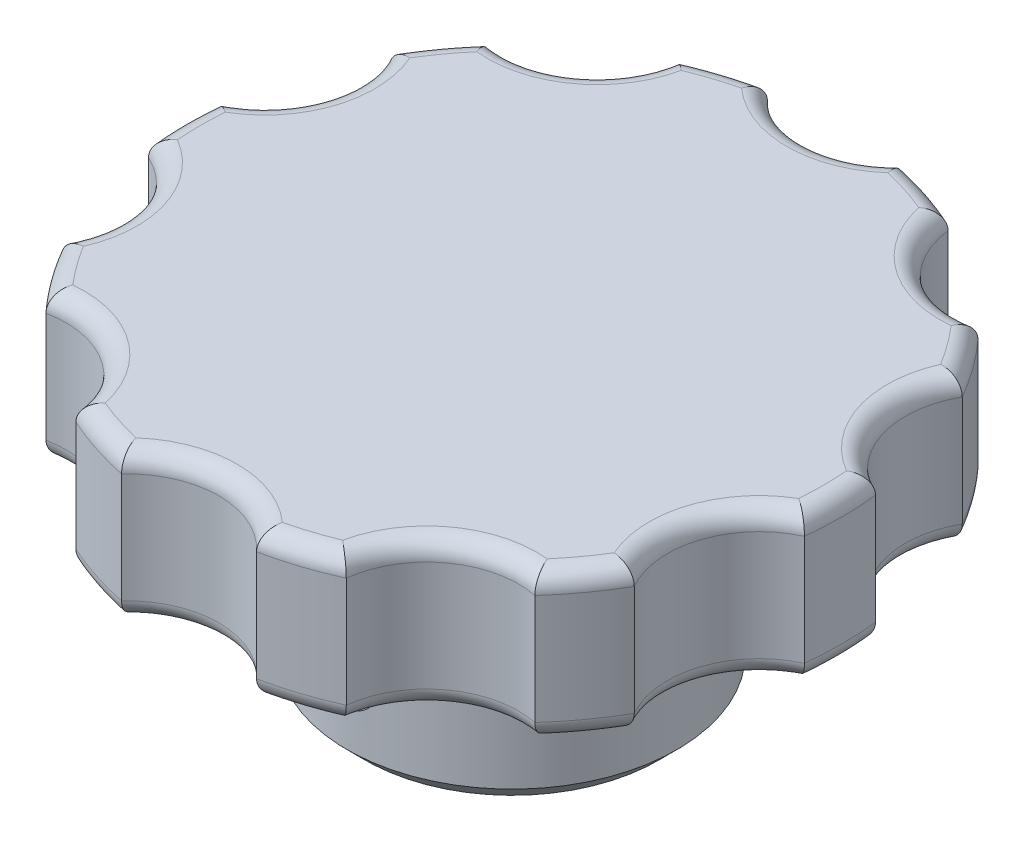
from build123d import *

# Parameters (mm, degrees)
CUT_EXTRUDE1_DEPTH = 18.5
CIRPATTERN1_COUNT  = 10
FILLET1_R          = 1
CHAMFER1_SIZE      = 1
SKETCH4_R          = 1.5
CUT_EXTRUDE2_DEPTH = 10


with BuildPart() as part:
    # Sketch1 → Revolve1 (revolve)
    with BuildSketch(Plane.XY):
        Polygon((-6, 0), (-6, 14), (0, 14), (0, 17.5), (-18, 17.5), (-18, 9.5), (-9, 9.5), (-9, 0), align=None)
    revolve(axis=Axis((0, 38.886792453, 0), (0, -1, 0)))

    # Sketch2 → Cut-Extrude1 (cut, through all)
    with BuildSketch(Plane(origin=(0, 17.5, 0), x_dir=(1, 0, 0), z_dir=(0, 1, 0))):
        with BuildLine():
            Line((-5, 21), (5, 21))
            ThreePointArc((5, 21), (0, 16), (-5, 21))
        make_face()
    cut_extrude1 = extrude(amount=-CUT_EXTRUDE1_DEPTH, mode=Mode.SUBTRACT)

    # CirPattern1: Cut-Extrude1 ×10 about axis
    cirpattern1_axis = Axis((0, 0, 0), (0, 1, 0))
    for i in range(1, CIRPATTERN1_COUNT):
        add(cut_extrude1.rotate(cirpattern1_axis, i * 360 / CIRPATTERN1_COUNT), mode=Mode.SUBTRACT)

    # Fillet1
    fillet1_edges = [part.edges().sort_by_distance(p)[0] for p in [
        (-9.404564037, 17.5, -12.94427191),
        (-5.562305899, 9.5, -17.119017293),
        (0, 9.5, -16),
        (-5.562305899, 17.5, -17.119017293),
        (0, 17.5, -16),
        (-14.562305899, 9.5, -10.580134541),
        (-18, 9.5, 0),
        (-14.562305899, 9.5, 10.580134541),
        (-5.562305899, 9.5, 17.119017293),
        (5.562305899, 9.5, 17.119017293),
        (14.562305899, 9.5, 10.580134541),
        (18, 9.5, 0),
        (14.562305899, 9.5, -10.580134541),
        (5.562305899, 9.5, -17.119017293),
        (-9.404564037, 9.5, -12.94427191),
        (-15.216904261, 9.5, -4.94427191),
        (-15.216904261, 9.5, 4.94427191),
        (-9.404564037, 9.5, 12.94427191),
        (0, 9.5, 16),
        (9.404564037, 9.5, 12.94427191),
        (15.216904261, 9.5, 4.94427191),
        (15.216904261, 9.5, -4.94427191),
        (9.404564037, 9.5, -12.94427191),
        (-14.562305899, 17.5, -10.580134541),
        (-18, 17.5, 0),
        (-14.562305899, 17.5, 10.580134541),
        (-5.562305899, 17.5, 17.119017293),
        (5.562305899, 17.5, 17.119017293),
        (14.562305899, 17.5, 10.580134541),
        (18, 17.5, 0),
        (14.562305899, 17.5, -10.580134541),
        (5.562305899, 17.5, -17.119017293),
        (9.404564037, 17.5, -12.94427191),
        (15.216904261, 17.5, -4.94427191),
        (9, 9.5, 0),
        (15.216904261, 17.5, 4.94427191),
        (9.404564037, 17.5, 12.94427191),
        (0, 17.5, 16),
        (-9.404564037, 17.5, 12.94427191),
        (-15.216904261, 17.5, 4.94427191),
        (-15.216904261, 17.5, -4.94427191),
    ]]
    fillet(fillet1_edges, radius=FILLET1_R)

    # Chamfer1
    chamfer1_edges = [part.edges().sort_by_distance(p)[0] for p in [
        (9, 0, 0),
    ]]
    chamfer(chamfer1_edges, length=CHAMFER1_SIZE)

    # Sketch4 → Cut-Extrude2 (cut)
    with BuildSketch(Plane.XY.offset(9)):
        with Locations((0, 4.5)):
            Circle(SKETCH4_R)
    extrude(amount=-CUT_EXTRUDE2_DEPTH, mode=Mode.SUBTRACT)


solid = part.part
